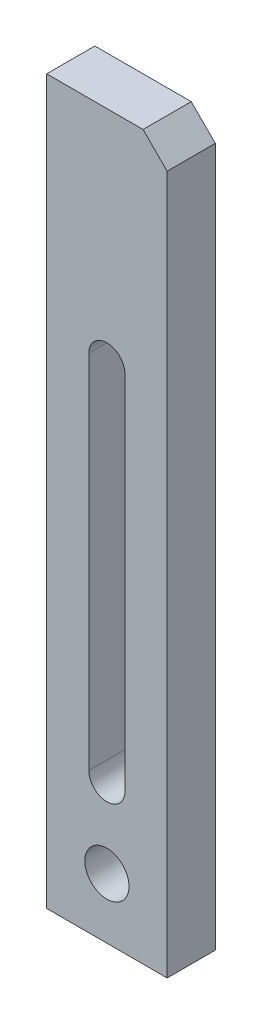
from build123d import *

# Parameters (mm, degrees)
SKETCH_1_W          = 30
SKETCH_1_H          = 180
EXTRUDE_1_DEPTH     = 12
SKETCH_2_R          = 5.5
CUT_EXTRUDE_1_DEPTH = 12
CHAMFER_1_SIZE      = 6


with BuildPart() as part:
    # 草图1 → 凸台-拉伸1 (new body)
    with BuildSketch(Plane.XY):
        Rectangle(SKETCH_1_W, SKETCH_1_H)
    extrude(amount=EXTRUDE_1_DEPTH)

    # 草图2 → 切除-拉伸1 (cut)
    with BuildSketch(Plane.XY.offset(12)):
        with Locations((0, -75)):
            Circle(SKETCH_2_R)
        with BuildLine():
            Line((4.5, 35), (4.5, -55))
            ThreePointArc((4.5, -55), (0, -59.5), (-4.5, -55))
            Line((-4.5, -55), (-4.5, 35))
            ThreePointArc((-4.5, 35), (0, 39.5), (4.5, 35))
        make_face()
    extrude(amount=-CUT_EXTRUDE_1_DEPTH, mode=Mode.SUBTRACT)

    # 倒角1
    chamfer_1_edges = [part.edges().sort_by_distance(p)[0] for p in [
        (15, 90, 6),
    ]]
    chamfer(chamfer_1_edges, length=CHAMFER_1_SIZE)


solid = part.part
